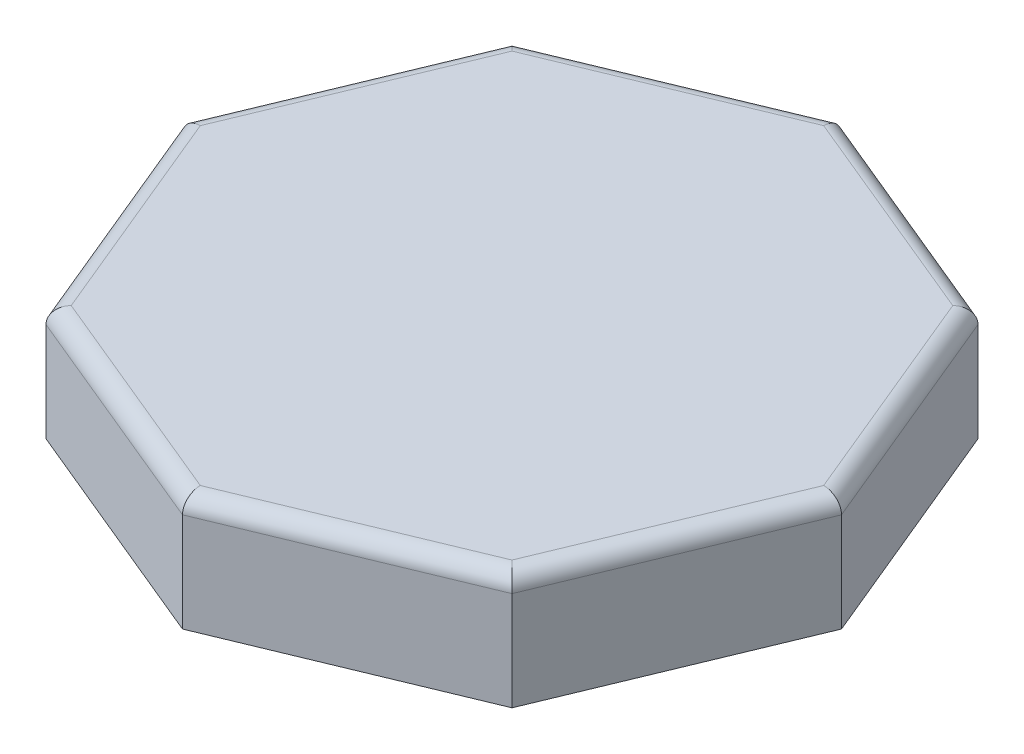
from build123d import *

# Parameters (mm, degrees)
BOSS_EXTRUDE1_DEPTH = 70
SHELL1_T            = -3
FILLET1_R           = 10
FILLET2_R           = 3


with BuildPart() as part:
    # Sketch3 → Boss-Extrude1 (new body)
    with BuildSketch(Plane(origin=(0, 0, 0), x_dir=(1, 0, 0), z_dir=(0, 1, 0))):
        Polygon((0, 199.904133626), (-141.353568474, 141.353568474), (-199.904133626, 0), (-141.353568474, -141.353568474), (0, -199.904133626), (141.353568474, -141.353568474), (199.904133626, 0), (141.353568474, 141.353568474), align=None)
    extrude(amount=BOSS_EXTRUDE1_DEPTH)

    # Shell1
    shell1_openings = [part.faces().sort_by_distance(p)[0] for p in [
        (0, 0, 0),
    ]]
    offset(amount=SHELL1_T, openings=shell1_openings, kind=Kind.INTERSECTION)

    # Fillet1
    fillet1_edges = [part.edges().sort_by_distance(p)[0] for p in [
        (170.62885105, 70, -70.676784237),
        (70.676784237, 70, -170.62885105),
        (-70.676784237, 70, -170.62885105),
        (-170.62885105, 70, -70.676784237),
        (-170.62885105, 70, 70.676784237),
        (-70.676784237, 70, 170.62885105),
        (70.676784237, 70, 170.62885105),
        (170.62885105, 70, 70.676784237),
    ]]
    fillet(fillet1_edges, radius=FILLET1_R)

    # Fillet2
    fillet2_edges = [part.edges().sort_by_distance(p)[0] for p in [
        (69.52873394, 67, 167.857212453),
        (167.857212453, 67, 69.52873394),
        (167.857212453, 67, -69.52873394),
        (69.52873394, 67, -167.857212453),
        (-69.52873394, 67, -167.857212453),
        (-167.857212453, 67, -69.52873394),
        (-167.857212453, 67, 69.52873394),
        (-69.52873394, 67, 167.857212453),
    ]]
    fillet(fillet2_edges, radius=FILLET2_R)


solid = part.part
